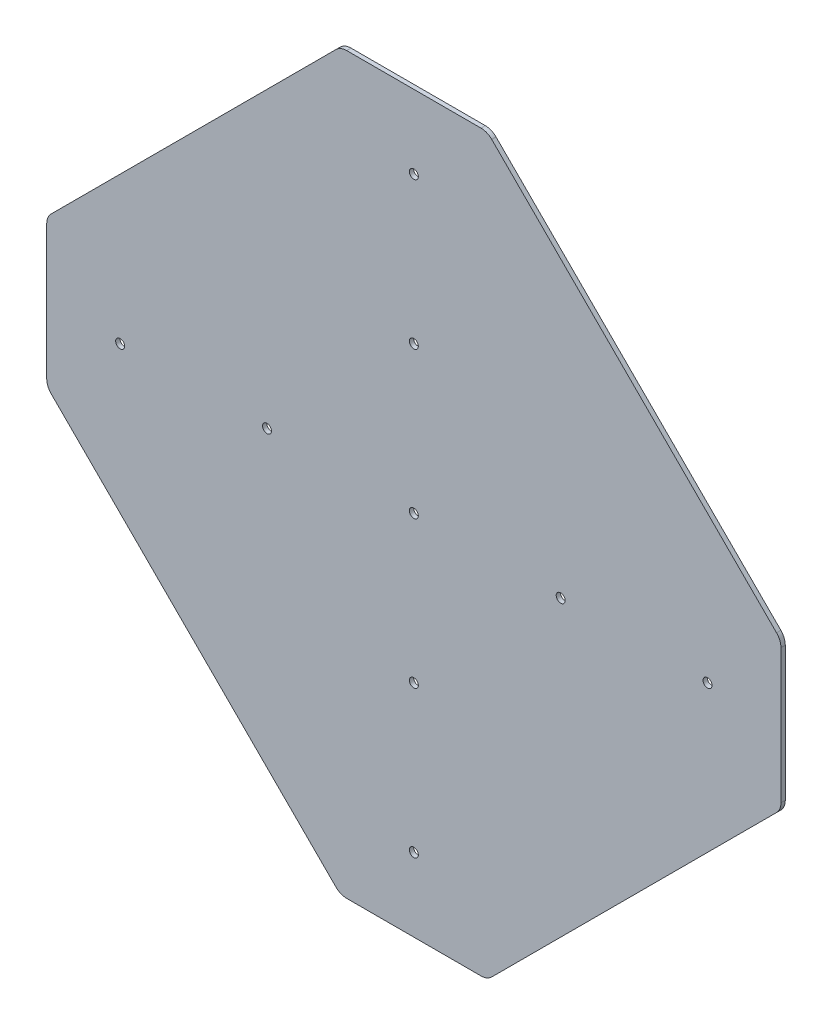
from build123d import *

# Parameters (mm, degrees)
SKETCH1_R           = 1.651
BOSS_EXTRUDE1_DEPTH = 1.5875


with BuildPart() as part:
    # Sketch1 → Boss-Extrude1 (new body)
    with BuildSketch(Plane(origin=(0, 0, 0), x_dir=(-1, 0, 0), z_dir=(0, 0, -1))):
        with BuildLine():
            Line((-133.310112052, -28.614887943), (-28.614887941, -133.310112054))
            ThreePointArc((-28.614887941, -133.310112054), (-26.812310708, -134.514555654), (-24.686025887, -134.937500002))
            Line((-24.686025887, -134.937500002), (24.68602589, -134.937500002))
            ThreePointArc((24.68602589, -134.937500002), (26.812310711, -134.514555654), (28.614887944, -133.310112054))
            Line((28.614887944, -133.310112054), (133.310112056, -28.614887942))
            ThreePointArc((133.310112056, -28.614887942), (134.514555656, -26.81231071), (134.937500003, -24.686025888))
            Line((134.937500003, -24.686025888), (134.937500003, 24.686025887))
            ThreePointArc((134.937500003, 24.686025887), (134.514555656, 26.812310709), (133.310112056, 28.614887942))
            Line((133.310112056, 28.614887942), (28.614887944, 133.310112054))
            ThreePointArc((28.614887944, 133.310112054), (26.812310711, 134.514555654), (24.68602589, 134.937500001))
            Line((24.68602589, 134.937500001), (-24.686025886, 134.937500001))
            ThreePointArc((-24.686025886, 134.937500001), (-26.812310708, 134.514555654), (-28.614887941, 133.310112054))
            Line((-28.614887941, 133.310112054), (-133.310112053, 28.614887942))
            ThreePointArc((-133.310112053, 28.614887942), (-134.514555652, 26.81231071), (-134.9375, 24.686025888))
            Line((-134.9375, 24.686025888), (-134.9375, -24.686025888))
            ThreePointArc((-134.9375, -24.686025888), (-134.514555652, -26.81231071), (-133.310112052, -28.614887943))
        make_face()
        with Locations((0, 53.975)):
            Circle(SKETCH1_R, mode=Mode.SUBTRACT)
        Circle(SKETCH1_R, mode=Mode.SUBTRACT)
        with Locations((0, -107.95)):
            Circle(SKETCH1_R, mode=Mode.SUBTRACT)
        with Locations((0, 107.95)):
            Circle(SKETCH1_R, mode=Mode.SUBTRACT)
        with Locations((-53.975, 0)):
            Circle(SKETCH1_R, mode=Mode.SUBTRACT)
        with Locations((53.975, 0)):
            Circle(SKETCH1_R, mode=Mode.SUBTRACT)
        with Locations((0, -53.975)):
            Circle(SKETCH1_R, mode=Mode.SUBTRACT)
        with Locations((-107.95, 0)):
            Circle(SKETCH1_R, mode=Mode.SUBTRACT)
        with Locations((107.95, 0)):
            Circle(SKETCH1_R, mode=Mode.SUBTRACT)
    extrude(amount=-BOSS_EXTRUDE1_DEPTH)


solid = part.part
